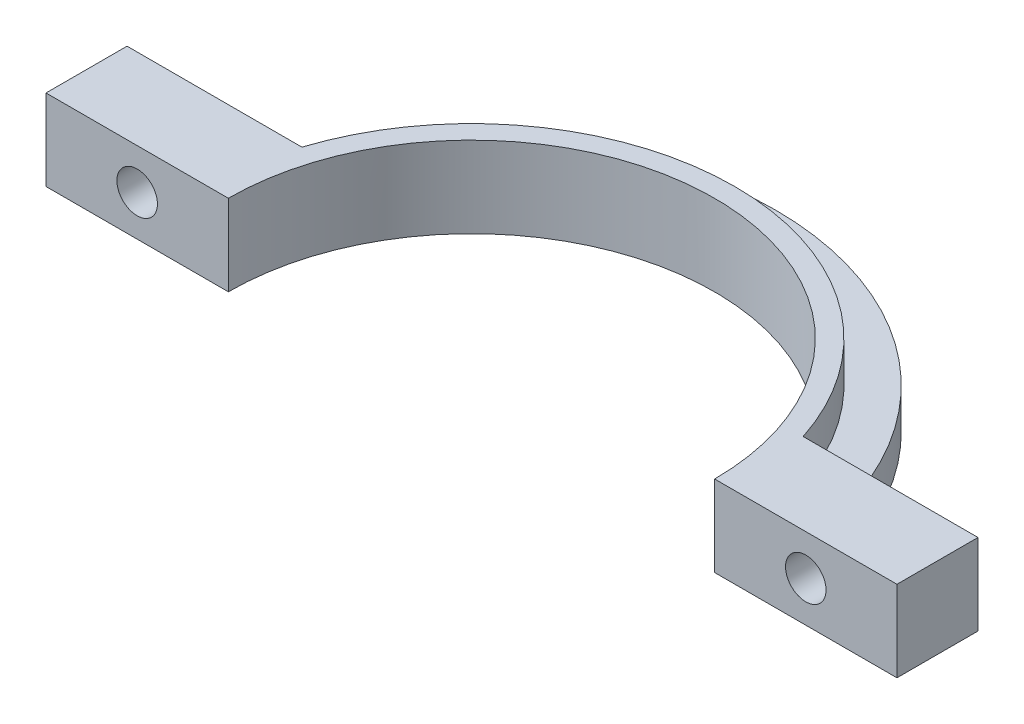
from build123d import *

# Parameters (mm, degrees)
BOSS_EXTRUDE1_DEPTH = 10
SKETCH3_R           = 2.5
CUT_EXTRUDE1_DEPTH  = 10
BOSS_EXTRUDE2_DEPTH = 5
SKETCH9_W           = 6.522192951
SKETCH9_H           = 3.955645811
BOSS_EXTRUDE3_DEPTH = 10
CHAMFER1_SIZE       = 1
SKETCH12_R          = 2
CUT_EXTRUDE4_DEPTH  = 10


with BuildPart() as part:
    # Sketch1 → Boss-Extrude1 (new body)
    with BuildSketch(Plane(origin=(0, 0, 0), x_dir=(1, 0, 0), z_dir=(0, 1, 0))):
        with BuildLine():
            Line((52.5, 10), (30.923292192, 10))
            ThreePointArc((30.923292192, 10), (0, 32.5), (-30.923292192, 10))
            Line((-30.923292192, 10), (-52.5, 10))
            Line((-52.5, 10), (-52.5, 0))
            Line((-52.5, 0), (-30, 0))
            ThreePointArc((-30, 0), (0, 30), (30, 0))
            Line((30, 0), (52.5, 0))
            Line((52.5, 0), (52.5, 10))
        make_face()
    extrude(amount=BOSS_EXTRUDE1_DEPTH)

    # Sketch3 → Cut-Extrude1 (cut)
    with BuildSketch(Plane.XY):
        with Locations((-41.25, 5)):
            Circle(SKETCH3_R)
        with Locations((41.25, 5)):
            Circle(SKETCH3_R)
    extrude(amount=-CUT_EXTRUDE1_DEPTH, mode=Mode.SUBTRACT)

    # Sketch5 → Boss-Extrude2 (add)
    with BuildSketch(Plane(origin=(0, 0, 0), x_dir=(1, 0, 0), z_dir=(0, 1, 0))):
        with BuildLine():
            ThreePointArc((37.5, 0), (0, 37.5), (-37.5, 0))
            Line((-37.5, 0), (-32.5, 0))
            ThreePointArc((-32.5, 0), (0, 32.5), (32.5, 0))
            Line((32.5, 0), (37.5, 0))
        make_face()
    extrude(amount=BOSS_EXTRUDE2_DEPTH)

    # Sketch9 → Boss-Extrude3 (add)
    with BuildSketch(Plane.XZ):
        with Locations((31.545367723, -11.977822906)):
            Rectangle(SKETCH9_W, SKETCH9_H)
    extrude(amount=BOSS_EXTRUDE3_DEPTH)

    # Chamfer1
    chamfer1_edges = [part.edges().sort_by_distance(p)[0] for p in [
        (28.284271247, -10, -11.977822906),
        (34.806464198, -10, -11.977822906),
    ]]
    chamfer(chamfer1_edges, length=CHAMFER1_SIZE)

    # Sketch12 → Cut-Extrude4 (cut)
    with BuildSketch(Plane(origin=(0, 0, -13.955645811), x_dir=(-1, 0, 0), z_dir=(0, 0, -1))):
        with Locations((-31.545367723, -6)):
            Circle(SKETCH12_R)
    extrude(amount=-CUT_EXTRUDE4_DEPTH, mode=Mode.SUBTRACT)


solid = part.part
